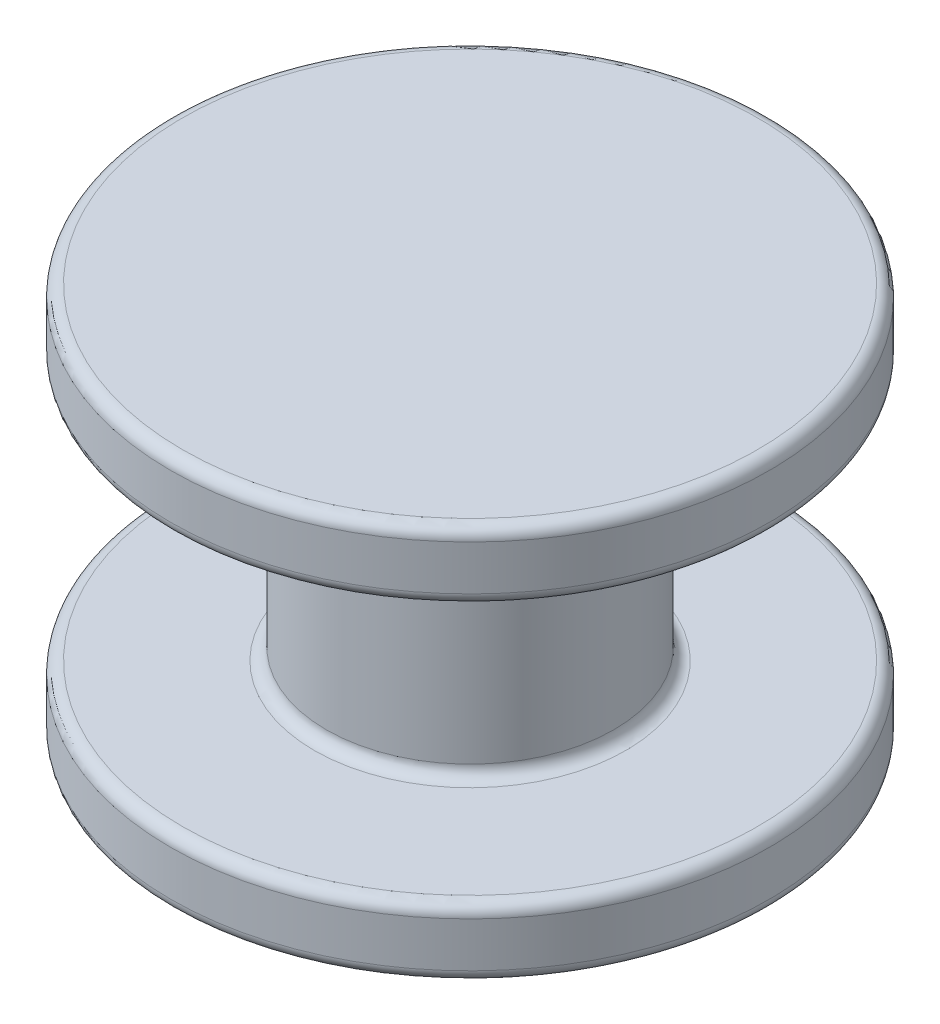
from build123d import *

# Parameters (mm, degrees)
SKETCH1_R           = 5
BOSS_EXTRUDE1_DEPTH = 1.15
SKETCH2_R           = 2.4
BOSS_EXTRUDE2_DEPTH = 4.3
SKETCH3_R           = 5
BOSS_EXTRUDE3_DEPTH = 1.15
FILLET1_R           = 0.2


with BuildPart() as part:
    # Sketch1 → Boss-Extrude1 (new body)
    with BuildSketch(Plane(origin=(0, 0, 0), x_dir=(1, 0, 0), z_dir=(0, 1, 0))):
        Circle(SKETCH1_R)
    extrude(amount=BOSS_EXTRUDE1_DEPTH)

    # Sketch2 → Boss-Extrude2 (add)
    with BuildSketch(Plane(origin=(0, 1.15, 0), x_dir=(1, 0, 0), z_dir=(0, 1, 0))):
        Circle(SKETCH2_R)
    extrude(amount=BOSS_EXTRUDE2_DEPTH)

    # Sketch3 → Boss-Extrude3 (add)
    with BuildSketch(Plane(origin=(0, 5.45, 0), x_dir=(1, 0, 0), z_dir=(0, 1, 0))):
        Circle(SKETCH3_R)
    extrude(amount=BOSS_EXTRUDE3_DEPTH)

    # Fillet1
    fillet1_edges = [part.edges().sort_by_distance(p)[0] for p in [
        (-5, 5.45, 0),
        (-5, 6.6, 0),
        (-5, 0, 0),
        (-5, 1.15, 0),
        (-2.4, 1.15, 0),
        (-2.4, 5.45, 0),
    ]]
    fillet(fillet1_edges, radius=FILLET1_R)


solid = part.part
